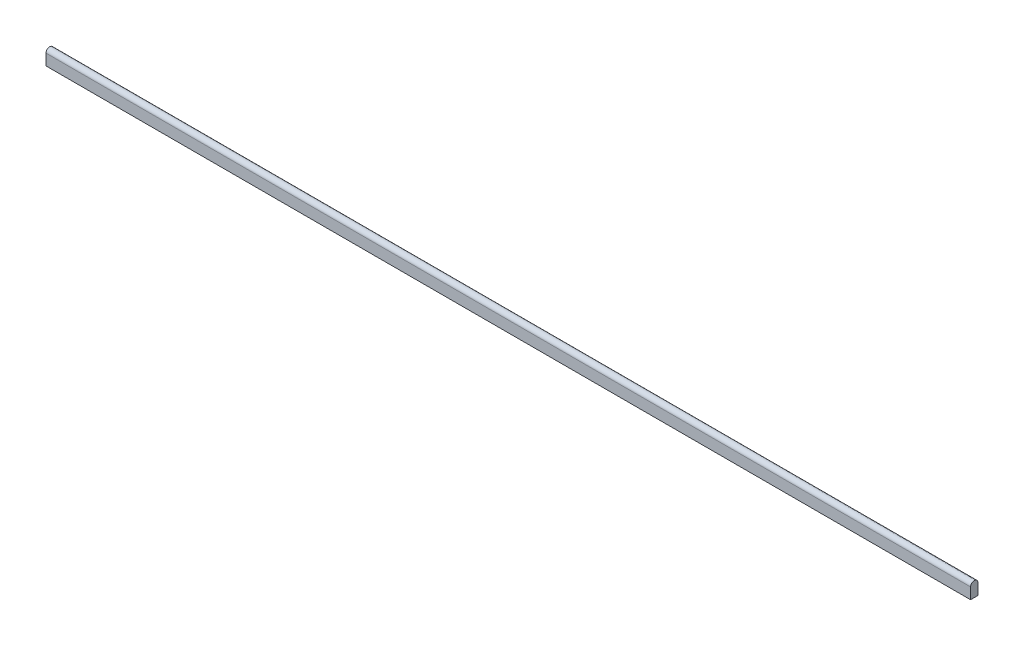
from build123d import *

# Parameters (mm, degrees)
EXTRUSION1_DEPTH = 500


with BuildPart() as part:
    # Esquisse1 → Extrusion1 (new body)
    with BuildSketch(Plane(origin=(0, 0, 0), x_dir=(0, 0, -1), z_dir=(1, 0, 0))):
        with BuildLine():
            Line((-2, 0), (-2, -6))
            Line((-2, -6), (2, -6))
            Line((2, -6), (2, 0))
            ThreePointArc((2, 0), (0, 2), (-2, 0))
        make_face()
    extrude(amount=EXTRUSION1_DEPTH)


solid = part.part
